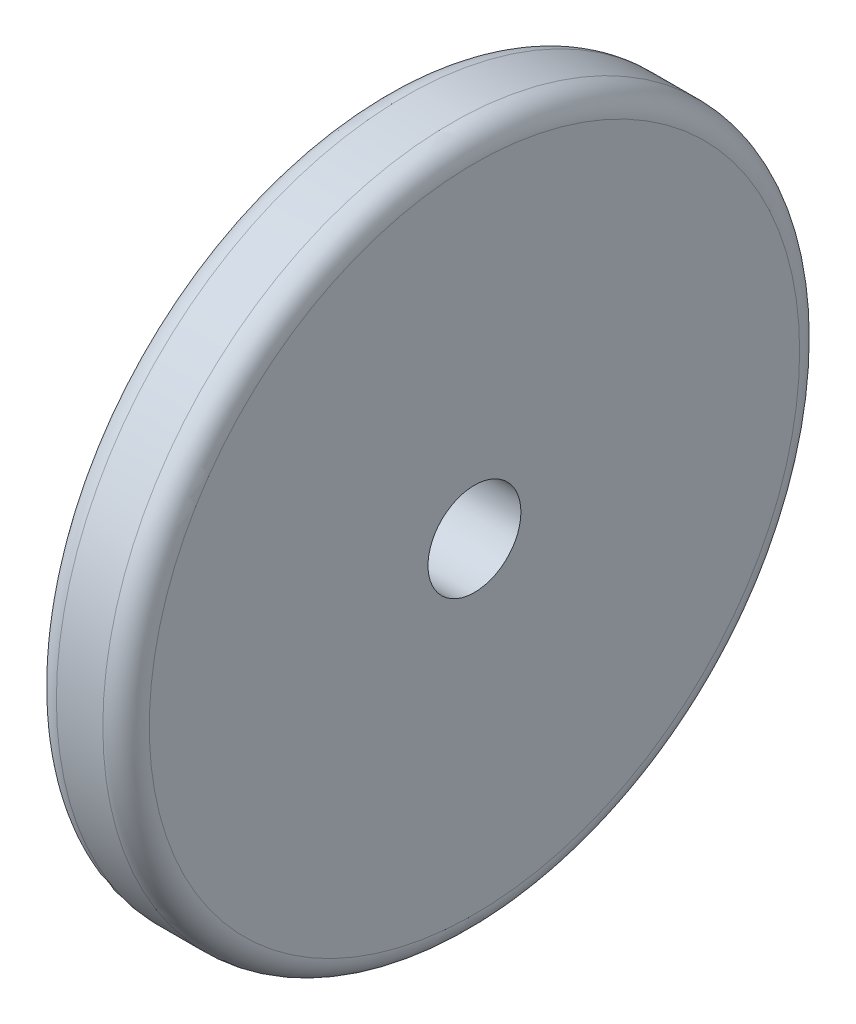
from build123d import *

# Parameters (mm, degrees)
SCHIZZO1_R                   = 30
ESTRUSIONE_ESTRUSIONE1_DEPTH = 8
SCHIZZO3_R                   = 4
TAGLIO_ESTRUSIONE1_DEPTH     = 9
RACCORDO1_R                  = 2


with BuildPart() as part:
    # Schizzo1 → Estrusione-Estrusione1 (new body)
    with BuildSketch(Plane(origin=(0, 0, 0), x_dir=(0, 0, -1), z_dir=(1, 0, 0))):
        Circle(SCHIZZO1_R)
    extrude(amount=ESTRUSIONE_ESTRUSIONE1_DEPTH)

    # Schizzo3 → Taglio-Estrusione1 (cut, through all)
    with BuildSketch(Plane(origin=(8, 0, 0), x_dir=(0, 0, -1), z_dir=(1, 0, 0))):
        Circle(SCHIZZO3_R)
    extrude(amount=-TAGLIO_ESTRUSIONE1_DEPTH, mode=Mode.SUBTRACT)

    # Raccordo1
    raccordo1_edges = [part.edges().sort_by_distance(p)[0] for p in [
        (0, 0, 30),
        (8, 0, 30),
    ]]
    fillet(raccordo1_edges, radius=RACCORDO1_R)


solid = part.part
